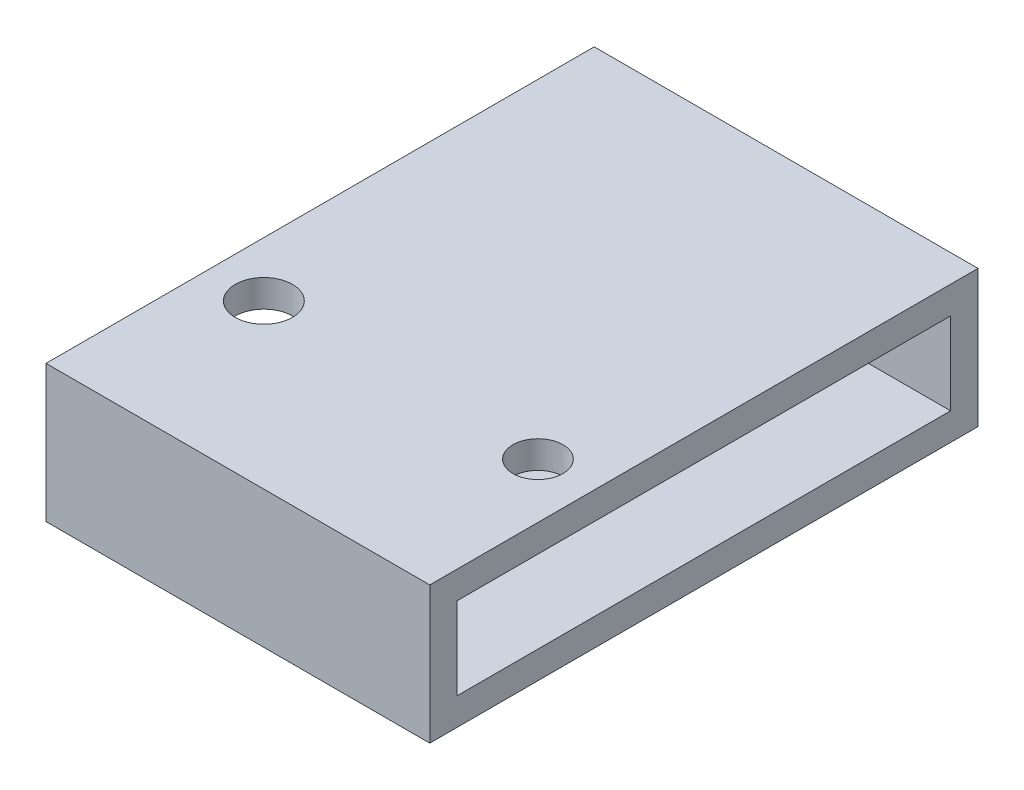
from build123d import *

# Parameters (mm, degrees)
SKETCH2_W           = 17.78
SKETCH2_H           = 25.4
BOSS_EXTRUDE1_DEPTH = 6.35
SKETCH3_R           = 1.326085058
SKETCH3_R_2         = 1.159154329
CUT_EXTRUDE2_DEPTH  = 3.81
CUT_EXTRUDE3_REACH  = 19.78
SKETCH4_W           = 22.86
SKETCH4_H           = 3.81


with BuildPart() as part:
    # Sketch2 → Boss-Extrude1 (new body)
    with BuildSketch(Plane(origin=(0, 0, 0), x_dir=(1, 0, 0), z_dir=(0, 1, 0))):
        with Locations((8.89, 12.7)):
            Rectangle(SKETCH2_W, SKETCH2_H)
    extrude(amount=BOSS_EXTRUDE1_DEPTH)

    # Sketch3 → Cut-Extrude2 (cut)
    with BuildSketch(Plane(origin=(0, 6.35, 0), x_dir=(1, 0, 0), z_dir=(0, 1, 0))):
        with Locations((2.54, 7.552937487)):
            Circle(SKETCH3_R)
        with Locations((15.24, 7.552937487)):
            Circle(SKETCH3_R_2)
    extrude(amount=-CUT_EXTRUDE2_DEPTH, mode=Mode.SUBTRACT)

    # Sketch4 → Cut-Extrude3 (cut, up to next)
    with BuildSketch(Plane(origin=(17.78, 0, 0), x_dir=(0, 0, -1), z_dir=(1, 0, 0)), mode=Mode.PRIVATE) as cut_extrude3_sk1:
        with Locations((12.7, 3.175)):
            Rectangle(SKETCH4_W, SKETCH4_H)
    cut_extrude3_tool1 = extrude(cut_extrude3_sk1.sketch, amount=-CUT_EXTRUDE3_REACH, mode=Mode.PRIVATE) & part.part
    add(cut_extrude3_tool1.solids().sort_by_distance((17.78, 3.175, -12.7))[0], mode=Mode.SUBTRACT)


solid = part.part
